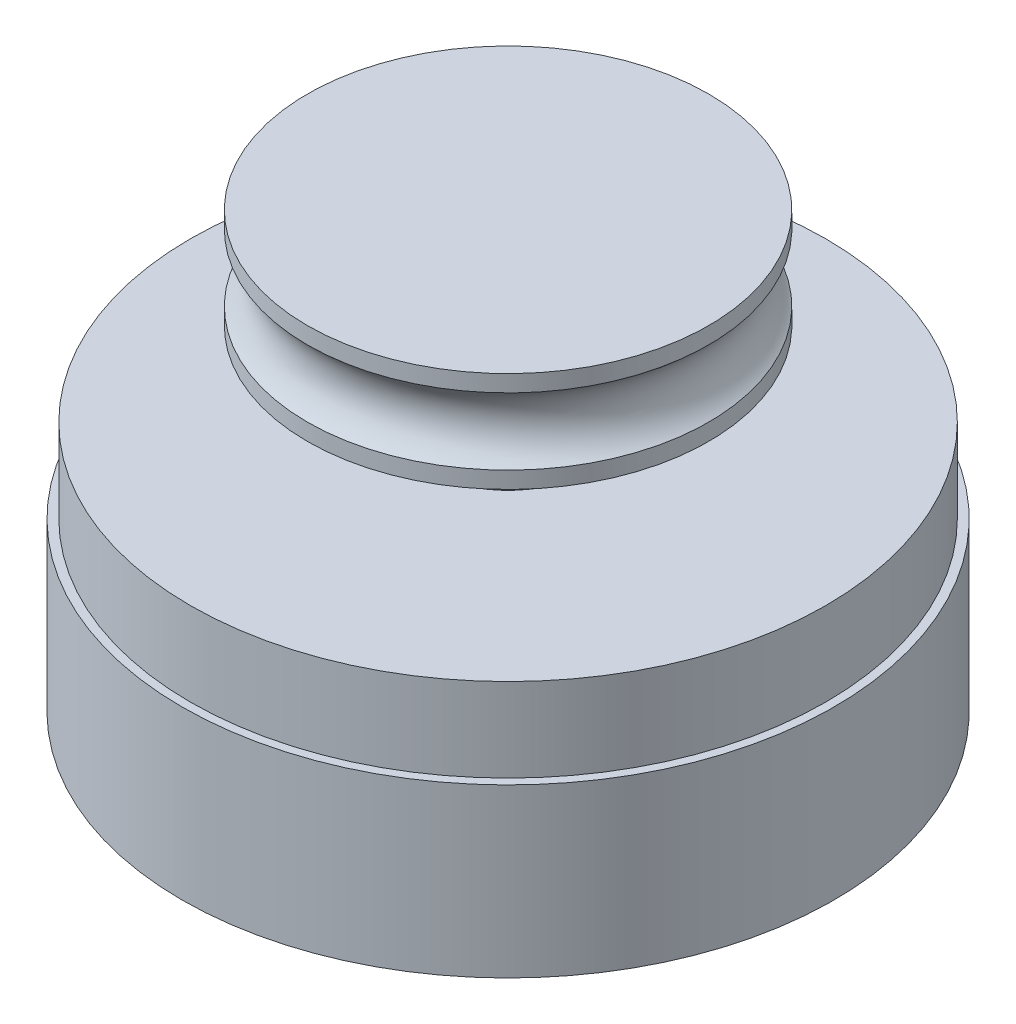
from build123d import *

# Parameters (mm, degrees)
SKETCH_1_R      = 19.5
EXTRUDE_1_DEPTH = 10
SKETCH_2_R      = 19
EXTRUDE_2_DEPTH = 5
SKETCH_3_R      = 5
EXTRUDE_3_DEPTH = 5


with BuildPart() as part:
    # 草图1 → 凸台-拉伸1 (new body)
    with BuildSketch(Plane(origin=(0, 0, 0), x_dir=(1, 0, 0), z_dir=(0, 1, 0))):
        Circle(SKETCH_1_R)
    extrude(amount=EXTRUDE_1_DEPTH)

    # 草图2 → 凸台-拉伸2 (add)
    with BuildSketch(Plane(origin=(0, 10, 0), x_dir=(1, 0, 0), z_dir=(0, 1, 0))):
        Circle(SKETCH_2_R)
    extrude(amount=EXTRUDE_2_DEPTH)

    # 草图3 → 凸台-拉伸3 (add)
    with BuildSketch(Plane(origin=(0, 15, 0), x_dir=(1, 0, 0), z_dir=(0, 1, 0))):
        Circle(SKETCH_3_R)
    extrude(amount=EXTRUDE_3_DEPTH)

    # 草图5 → 旋转1 (revolve)
    with BuildSketch(Plane.XY):
        with BuildLine():
            Line((0, 20), (0, 26))
            Line((0, 26), (12, 26))
            Line((12, 26), (12, 25))
            ThreePointArc((12, 25), (11, 23), (12, 21))
            Line((12, 21), (12, 20))
            Line((12, 20), (0, 20))
        make_face()
    revolve(axis=Axis((0, 20, 0), (0, 1, 0)))


solid = part.part
